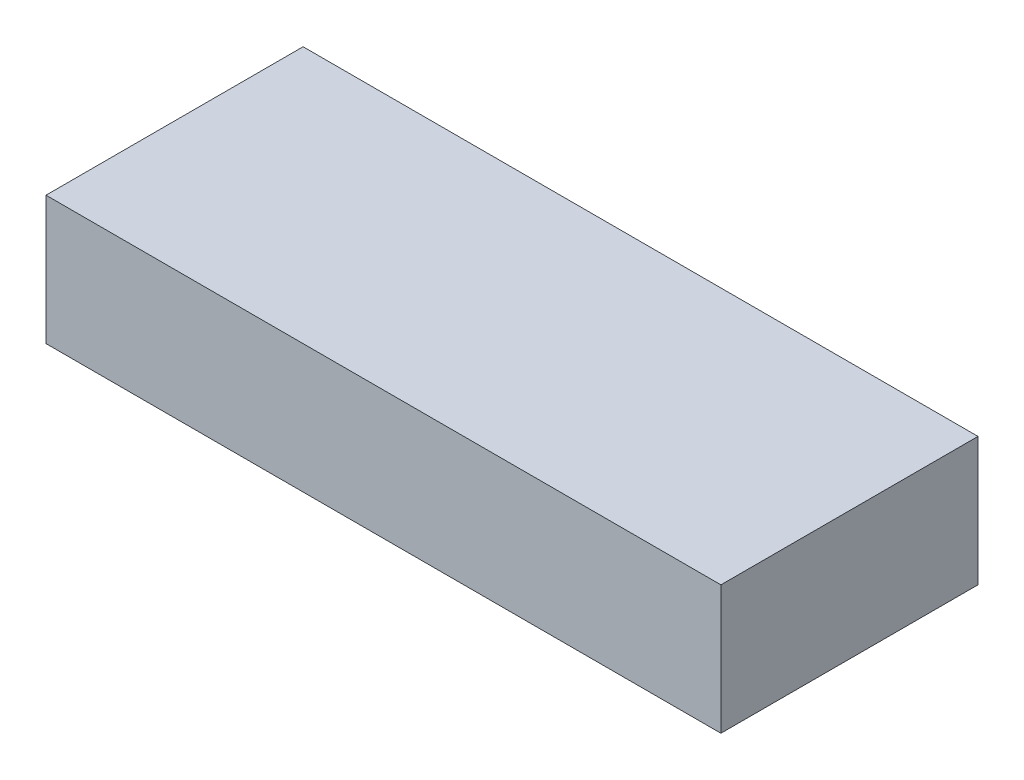
from build123d import *

# Parameters (mm, degrees)
SKETCH2_W           = 133.35
SKETCH2_H           = 50.8
BOSS_EXTRUDE1_DEPTH = 25.4


with BuildPart() as part:
    # Sketch2 → Boss-Extrude1 (new body)
    with BuildSketch(Plane(origin=(0, 0, 0), x_dir=(1, 0, 0), z_dir=(0, 1, 0))):
        Rectangle(SKETCH2_W, SKETCH2_H)
    extrude(amount=BOSS_EXTRUDE1_DEPTH)


solid = part.part
